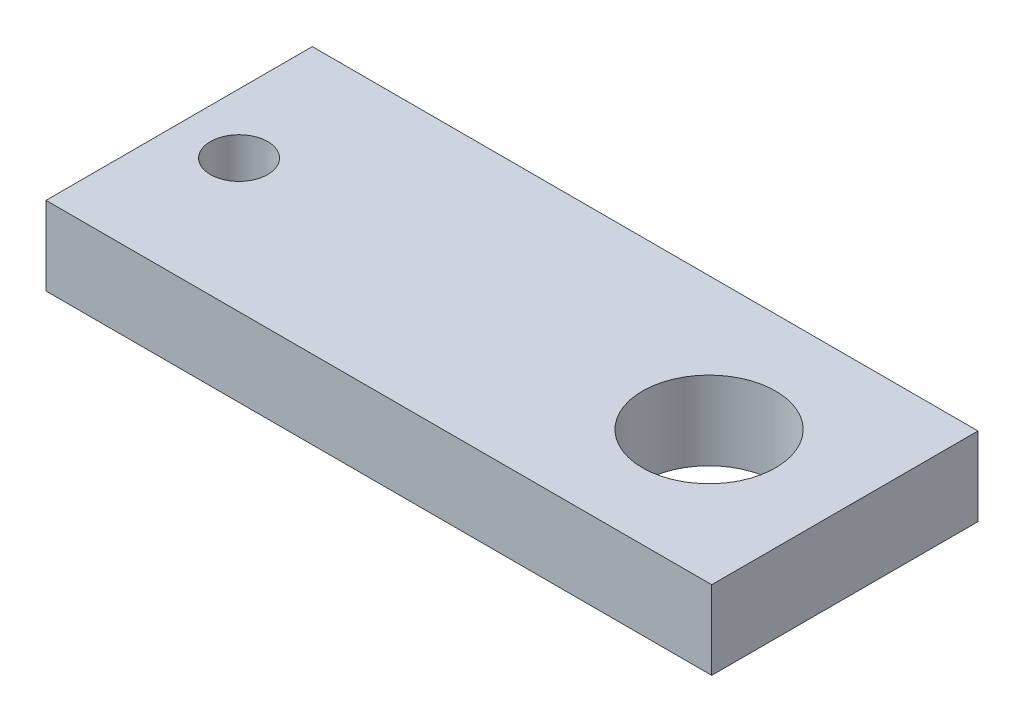
from build123d import *

# Parameters (mm, degrees)
SKETCH1_W           = 50
SKETCH1_H           = 20
SKETCH1_R           = 5
SKETCH1_R_2         = 2.15
BOSS_EXTRUDE1_DEPTH = 5.9


with BuildPart() as part:
    # Sketch1 → Boss-Extrude1 (new body)
    with BuildSketch(Plane(origin=(0, 0, 0), x_dir=(1, 0, 0), z_dir=(0, 1, 0))):
        Rectangle(SKETCH1_W, SKETCH1_H)
        with Locations((14.8, 0)):
            Circle(SKETCH1_R, mode=Mode.SUBTRACT)
        with Locations((-20.5, 0)):
            Circle(SKETCH1_R_2, mode=Mode.SUBTRACT)
    extrude(amount=BOSS_EXTRUDE1_DEPTH)


solid = part.part
